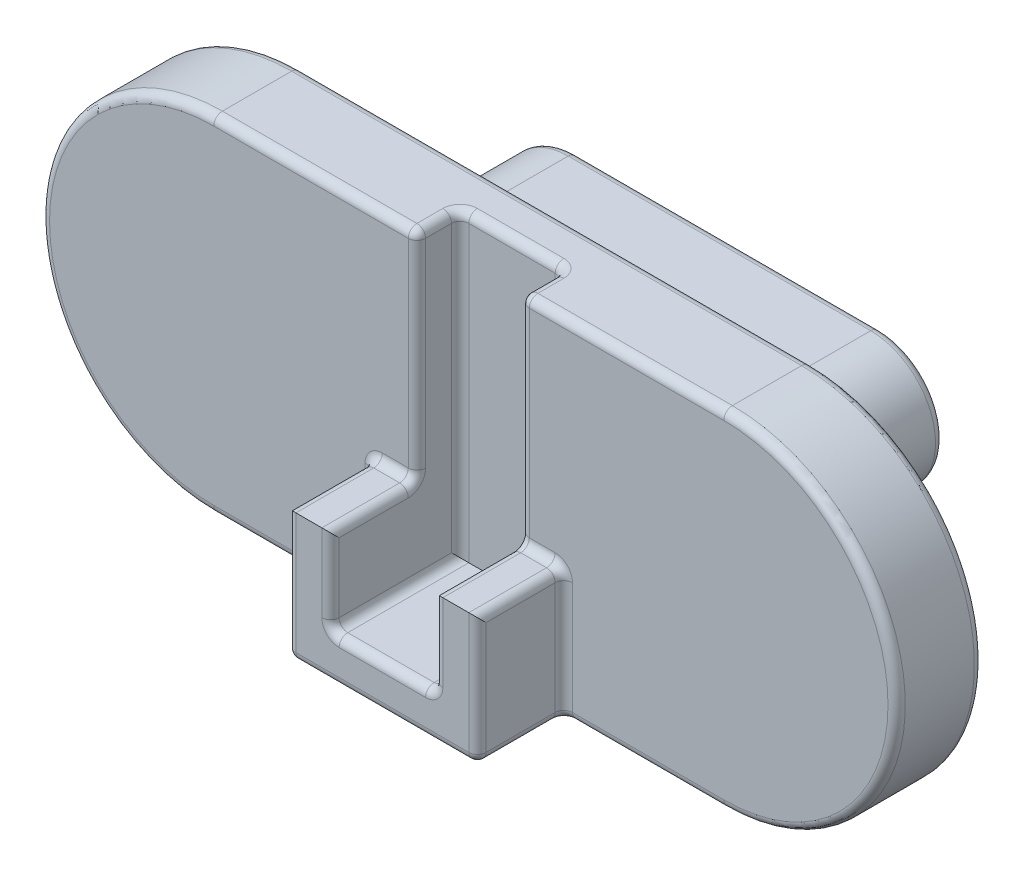
from build123d import *

# Parameters (mm, degrees)
DODANIE_WYCI_GNI_CIE1_DEPTH = 1
DODANIE_WYCI_GNI_CIE2_DEPTH = 2
DODANIE_WYCI_GNI_CIE3_DEPTH = 1
SZKIC4_W                    = 1.2
SZKIC4_H                    = 0.5
WYTNIJ_WYCI_GNI_CIE1_DEPTH  = 3.5
ZAOKR_GLENIE1_R             = 0.1


with BuildPart() as part:
    # Szkic1 → Dodanie-wyciągnięcie1 (new body)
    with BuildSketch(Plane.XY):
        with BuildLine():
            Line((0, 2), (5.9, 2))
            ThreePointArc((5.9, 2), (7.9, 0), (5.9, -2))
            Line((5.9, -2), (0, -2))
            ThreePointArc((0, -2), (-2, 0), (0, 2))
        make_face()
    extrude(amount=DODANIE_WYCI_GNI_CIE1_DEPTH)

    # Szkic2 → Dodanie-wyciągnięcie2 (add)
    with BuildSketch(Plane(origin=(0, 0, 0), x_dir=(-1, 0, 0), z_dir=(0, 0, -1))):
        with BuildLine():
            Line((-1.2, -0.75), (-4.7, -0.75))
            ThreePointArc((-4.7, -0.75), (-5.45, 0), (-4.7, 0.75))
            Line((-4.7, 0.75), (-1.2, 0.75))
            ThreePointArc((-1.2, 0.75), (-0.45, 0), (-1.2, -0.75))
        make_face()
    extrude(amount=DODANIE_WYCI_GNI_CIE2_DEPTH)

    # Szkic3 → Dodanie-wyciągnięcie3 (add)
    with BuildSketch(Plane.XY.offset(1)):
        Polygon((2.35, -1.5), (3.55, -1.5), (3.55, -0.5), (4.05, -0.5), (4.05, -2), (1.85, -2), (1.85, -0.5), (2.35, -0.5), align=None)
    extrude(amount=DODANIE_WYCI_GNI_CIE3_DEPTH)

    # Szkic4 → Wytnij-wyciągnięcie1 (cut)
    with BuildSketch(Plane(origin=(0, 2, 0), x_dir=(1, 0, 0), z_dir=(0, 1, 0))):
        with Locations((2.95, -0.75)):
            Rectangle(SZKIC4_W, SZKIC4_H)
    extrude(amount=-WYTNIJ_WYCI_GNI_CIE1_DEPTH, mode=Mode.SUBTRACT)

    # Zaokrąglenie1
    zaokr_glenie1_edges = [part.edges().sort_by_distance(p)[0] for p in [
        (7.9, 0, 1),
        (0.45, 0, 0),
        (2.95, 0.75, 0),
        (5.45, 0, 0),
        (2.95, -0.75, 0),
        (4.725, 2, 1),
        (0.45, 0, -2),
        (2.95, 0.75, -2),
        (5.45, 0, -2),
        (2.95, -0.75, -2),
        (4.975, -2, 1),
        (2.35, -1.5, 1.25),
        (2.1, -0.5, 1),
        (2.35, -0.5, 1.5),
        (1.85, -1.25, 1),
        (1.85, -0.5, 1.5),
        (1.85, -2, 1.5),
        (4.05, -1.25, 1),
        (4.05, -2, 1.5),
        (3.8, -0.5, 1),
        (4.05, -0.5, 1.5),
        (3.55, -0.5, 1.5),
        (3.55, -1.5, 1.25),
        (2.35, -1, 2),
        (1.85, -1.25, 2),
        (2.95, -2, 2),
        (4.05, -1.25, 2),
        (3.55, -1, 2),
        (2.95, -1.5, 2),
        (1.175, 2, 1),
        (-2, 0, 1),
        (2.95, 2, 0),
        (3.55, 2, 0.75),
        (2.95, 2, 0.5),
        (2.35, 2, 0.75),
        (2.35, 0.25, 0.5),
        (2.35, 0.75, 1),
        (3.55, 0.75, 1),
        (3.55, 0.25, 0.5),
        (7.9, 0, 0),
        (2.95, -2, 0),
        (-2, 0, 0),
        (0.925, -2, 1),
    ]]
    fillet(zaokr_glenie1_edges, radius=ZAOKR_GLENIE1_R)


solid = part.part
